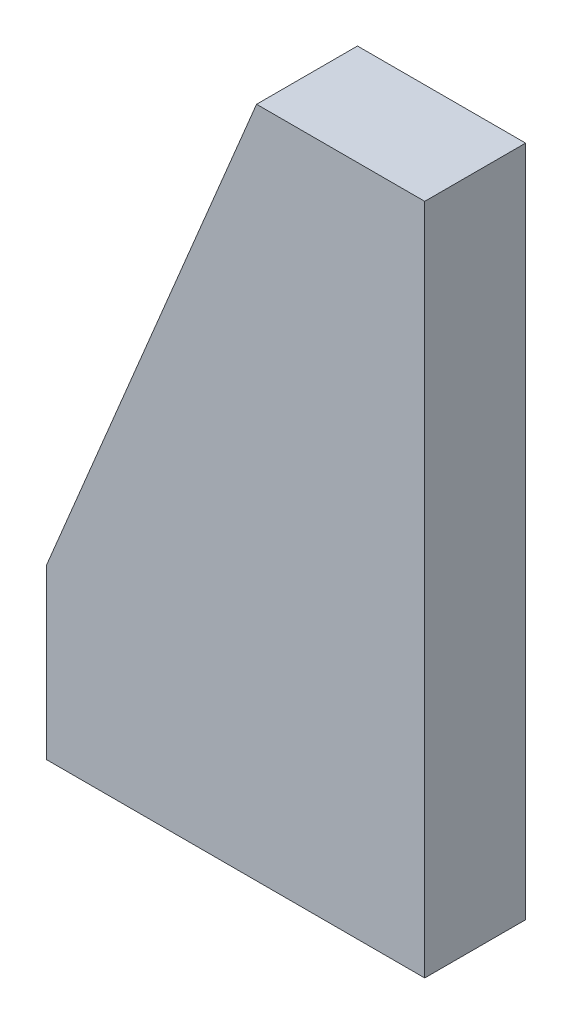
from build123d import *

# Parameters (mm, degrees)
EXTRUDE1_DEPTH = 12


with BuildPart() as part:
    # Sketch1 → Extrude1 (new body)
    with BuildSketch(Plane.XY):
        Polygon((0, 0), (45, 0), (45, 80), (25, 80), (0, 20), align=None)
    extrude(amount=EXTRUDE1_DEPTH)


solid = part.part
